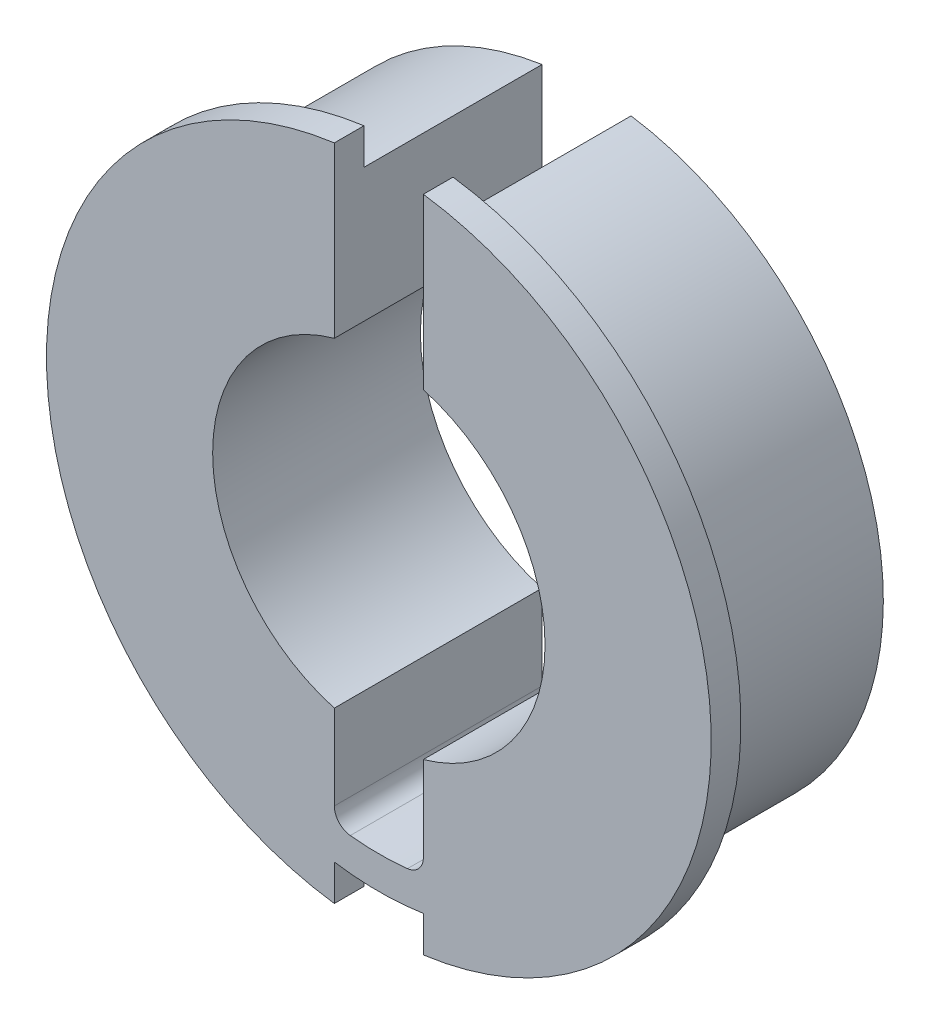
from build123d import *

# Parameters (mm, degrees)
SKETCH1_R           = 12.7
SKETCH1_R_2         = 7.112
BOSS_EXTRUDE1_DEPTH = 7.62
SKETCH2_R           = 14.224
SKETCH2_R_2         = 7.112
BOSS_EXTRUDE2_DEPTH = 1.27
CUT_EXTRUDE1_DEPTH  = 9.89
CUT_EXTRUDE2_DEPTH  = 2.27
FILLET1_R           = 0.762


with BuildPart() as part:
    # Sketch1 → Boss-Extrude1 (new body)
    with BuildSketch(Plane.XY):
        Circle(SKETCH1_R)
        Circle(SKETCH1_R_2, mode=Mode.SUBTRACT)
    extrude(amount=BOSS_EXTRUDE1_DEPTH)

    # Sketch2 → Boss-Extrude2 (add)
    with BuildSketch(Plane.XY.offset(7.62)):
        Circle(SKETCH2_R)
        Circle(SKETCH2_R_2, mode=Mode.SUBTRACT)
    extrude(amount=BOSS_EXTRUDE2_DEPTH)

    # Sketch3 → Cut-Extrude1 (cut, through all)
    with BuildSketch(Plane(origin=(0, 0, 0), x_dir=(-1, 0, 0), z_dir=(0, 0, -1))):
        with BuildLine():
            Line((-1.905, 14.224), (1.905, 14.224))
            Line((1.905, 14.224), (1.905, -11.141309797))
            ThreePointArc((1.905, -11.141309797), (0, -11.303), (-1.905, -11.141309797))
            Line((-1.905, -11.141309797), (-1.905, 14.224))
        make_face()
    extrude(amount=-CUT_EXTRUDE1_DEPTH, mode=Mode.SUBTRACT)

    # Sketch4 → Cut-Extrude2 (cut, through all)
    with BuildSketch(Plane(origin=(0, 0, 7.62), x_dir=(-1, 0, 0), z_dir=(0, 0, -1))):
        with BuildLine():
            Line((-1.905, -14.224), (-1.905, -12.556312158))
            ThreePointArc((-1.905, -12.556312158), (0, -12.7), (1.905, -12.556312158))
            Line((1.905, -12.556312158), (1.905, -14.224))
            Line((1.905, -14.224), (-1.905, -14.224))
        make_face()
    extrude(amount=-CUT_EXTRUDE2_DEPTH, mode=Mode.SUBTRACT)

    # Fillet1
    fillet1_edges = [part.edges().sort_by_distance(p)[0] for p in [
        (1.905, -11.141309797, 4.445),
        (-1.905, -11.141309797, 4.445),
    ]]
    fillet(fillet1_edges, radius=FILLET1_R)


solid = part.part
